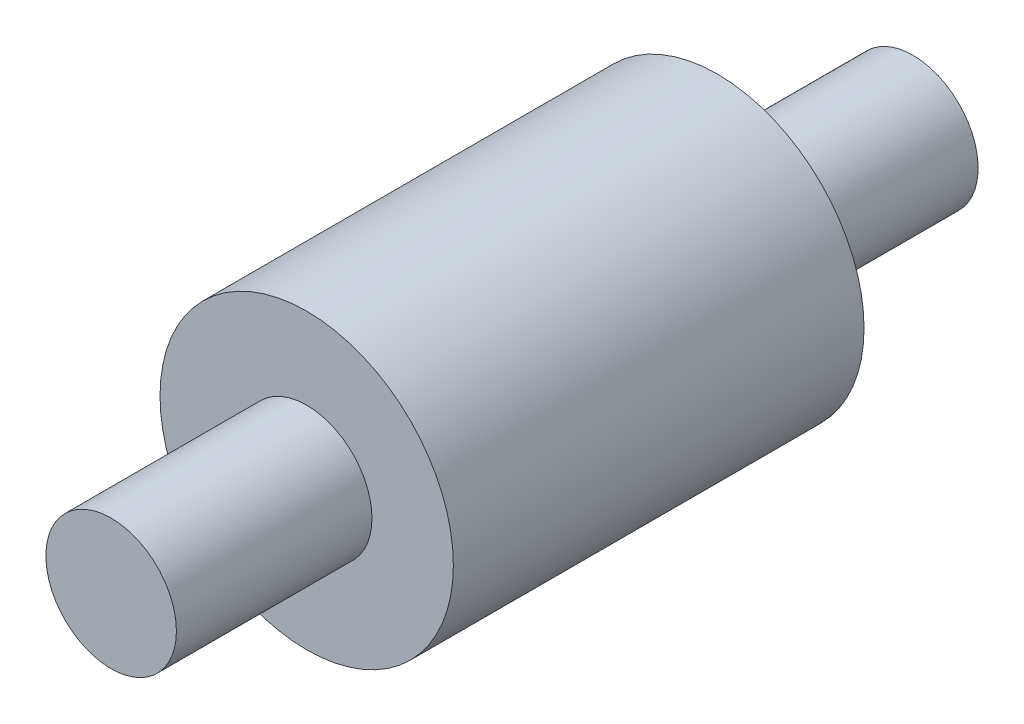
from build123d import *

# Parameters (mm, degrees)
SKETCH1_R           = 2.25
BOSS_EXTRUDE1_DEPTH = 6.3
SKETCH2_R           = 1.001216146
BOSS_EXTRUDE2_DEPTH = 3
SKETCH3_R           = 1
BOSS_EXTRUDE3_DEPTH = 3


with BuildPart() as part:
    # Sketch1 → Boss-Extrude1 (new body)
    with BuildSketch(Plane.XY):
        Circle(SKETCH1_R)
    extrude(amount=BOSS_EXTRUDE1_DEPTH)

    # Sketch2 → Boss-Extrude2 (add)
    with BuildSketch(Plane.XY.offset(6.3)):
        Circle(SKETCH2_R)
    extrude(amount=BOSS_EXTRUDE2_DEPTH)

    # Sketch3 → Boss-Extrude3 (add)
    with BuildSketch(Plane(origin=(0, 0, 0), x_dir=(-1, 0, 0), z_dir=(0, 0, -1))):
        Circle(SKETCH3_R)
    extrude(amount=BOSS_EXTRUDE3_DEPTH)


solid = part.part
